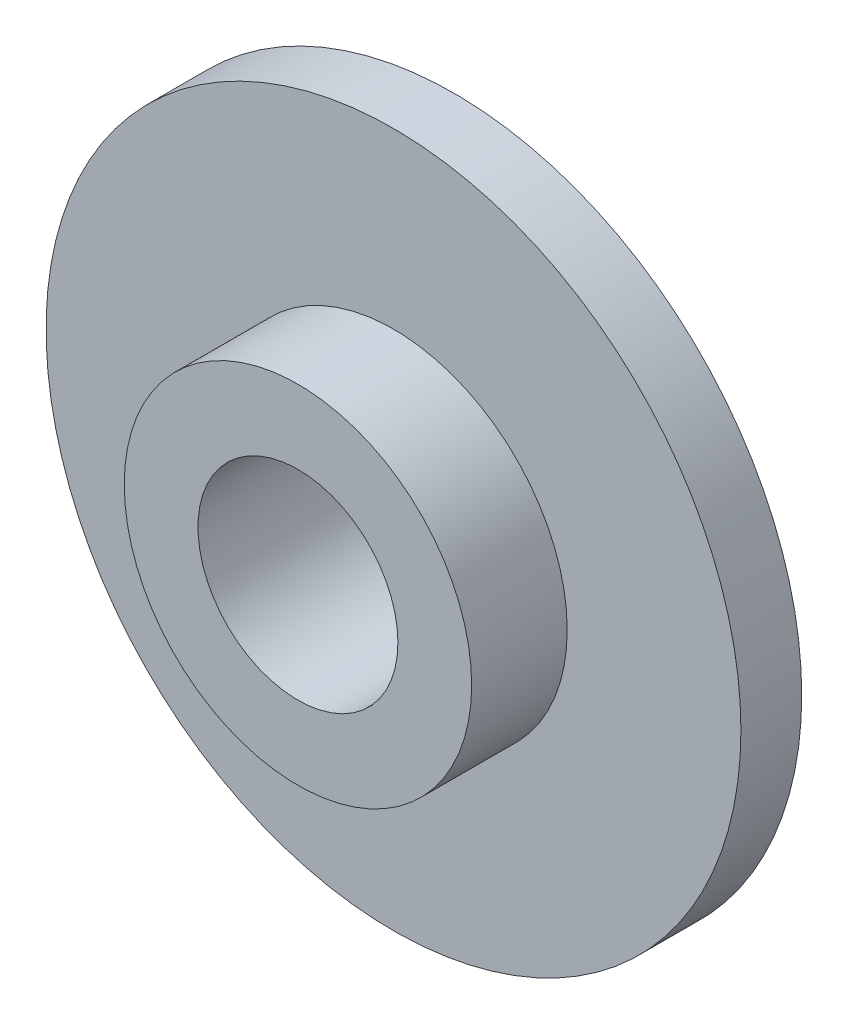
from build123d import *

# Parameters (mm, degrees)
SKETCH1_R           = 10.16
BOSS_EXTRUDE1_DEPTH = 1.778
SKETCH2_R           = 5.08
BOSS_EXTRUDE2_DEPTH = 2.794
SKETCH3_R           = 2.923457499
CUT_EXTRUDE1_DEPTH  = 4.572


with BuildPart() as part:
    # Sketch1 → Boss-Extrude1 (new body)
    with BuildSketch(Plane.XY):
        Circle(SKETCH1_R)
    extrude(amount=BOSS_EXTRUDE1_DEPTH)

    # Sketch2 → Boss-Extrude2 (add)
    with BuildSketch(Plane.XY.offset(1.778)):
        Circle(SKETCH2_R)
    extrude(amount=BOSS_EXTRUDE2_DEPTH)

    # Sketch3 → Cut-Extrude1 (cut)
    with BuildSketch(Plane.XY.offset(4.572)):
        Circle(SKETCH3_R)
    extrude(amount=-CUT_EXTRUDE1_DEPTH, mode=Mode.SUBTRACT)


solid = part.part
